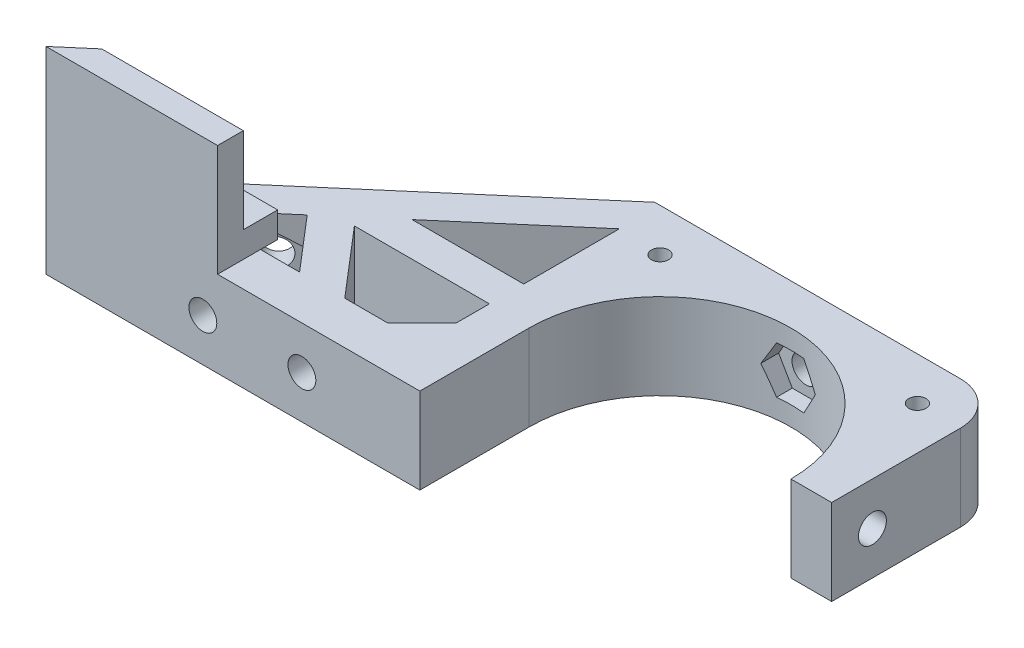
from build123d import *

# Parameters (mm, degrees)
CROQUIS1_R                              = 15.25
CROQUIS1_R_2                            = 2.125
SOPORTE_CAJA_REDUCTORA_DEPTH            = 20
CROQUIS3_R                              = 2.125
CORTAR_EXTRUIR1_DEPTH                   = 51.423828692
REDONDEO1_R                             = 5
BOSS_EXTRUDE1_DEPTH                     = 20
CUT_EXTRUDE1_REACH                      = 55.852
SKETCH2_R                               = 1.625
CUT_EXTRUDE2_DEPTH                      = 2
SKETCH4_R                               = 1.625
CUT_EXTRUDE3_DEPTH                      = 63.291652731
CUT_EXTRUDE4_START                      = -4.5
CUT_EXTRUDE4_DEPTH                      = 2
CROQUIS6_W                              = 4.75
CROQUIS6_H                              = 4.75
CORTAR_EXTRUIR17_DEPTH                  = 42.231056256
CROQUIS7_W                              = 60
CROQUIS7_H                              = 20
CORTAR_EXTRUIR18_DEPTH                  = 51.423828692
SALIENTE_EXTRUIR2_DEPTH                 = 49
SOPORTE_START                           = -15
SOPORTE_MOTOR_DEPTH                     = 15
CROQUIS12_R                             = 2.125
AGUJEROS_DE_SUJECION_A_BASE_DEPTH       = 84.087679592
TUERCA_START                            = -4
TUERCA_AGUJERO_DE_SUJECION_A_BASE_DEPTH = 10
SALIENTE_EXTRUIR4_DEPTH                 = 15
CORTAR_EXTRUIR19_DEPTH                  = 25
CROQUIS14_W                             = 50
CROQUIS14_H                             = 118
CORTAR_EXTRUIR22_DEPTH                  = 146.556045907
CROQUIS15_W                             = 10
CROQUIS15_H                             = 7
CORTAR_EXTRUIR23_DEPTH                  = 42.231056256
CORTAR_EXTRUIR24_DEPTH                  = 42.231056256
CROQUIS18_W                             = 40
CROQUIS18_H                             = 10
CORTAR_EXTRUIR25_DEPTH                  = 44.27311521
SALIENTE_EXTRUIR5_DEPTH                 = 10
CROQUIS20_R                             = 1
CORTAR_EXTRUIR26_DEPTH                  = 49.229270158
CORTAR_EXTRUIR27_REACH                  = 62.959
CORTAR_EXTRUIR27_END_RADIUS             = 15.25
CROQUIS21_R                             = 1.625
CROQUIS22_R                             = 2.125
CROQUIS22_R_2                           = 1
SALIENTE_EXTRUIR6_DEPTH                 = 10
CROQUIS23_R                             = 1.625
CORTAR_EXTRUIR28_DEPTH                  = 52.269508521
CORTAR_EXTRUIR29_START                  = -3
CORTAR_EXTRUIR29_DEPTH                  = 10
SALIENTE_EXTRUIR7_DEPTH                 = 10
CORTAR_EXTRUIR30_REACH                  = 72.235
CROQUIS27_R                             = 1.625
CORTAR_EXTRUIR31_REACH                  = 75.235
CORTAR_EXTRUIR31_START                  = -3
CORTAR_EXTRUIR32_REACH                  = 58.612
CROQUIS29_R                             = 1.625
CORTAR_EXTRUIR33_REACH                  = 61.112
CORTAR_EXTRUIR33_START                  = -2.5
CROQUIS35_W                             = 13.305418987
CROQUIS35_H                             = 6.826864192
CORTAR_EXTRUIR34_DEPTH                  = 63.931555098
CORTAR_EXTRUIR34_DEPTH_BACK             = 63.931555098
CORTAR_EXTRUIR35_START                  = -3
CORTAR_EXTRUIR35_DEPTH                  = 10
SALIENTE_EXTRUIR8_DEPTH                 = 10
SALIENTE_EXTRUIR9_DEPTH                 = 13
SALIENTE_EXTRUIR10_DEPTH                = 3
CROQUIS40_W                             = 106.583537839
CROQUIS40_H                             = 47.391515964
CORTAR_EXTRUIR36_DEPTH                  = 80.887064817
CORTAR_EXTRUIR36_DEPTH_BACK             = 80.887064817


with BuildPart() as part:
    # Croquis1 → Soporte caja reductora (new body)
    with BuildSketch(Plane(origin=(0, 0, 0), x_dir=(1, 0, 0), z_dir=(0, 1, 0))):
        Polygon((-30, -15.25), (-20, -15.25), (-20, -20), (20, -20), (20, -15.25), (30, -15.25), (30, -7.25), (20, -4.25), (20, 20), (-20, 20), (-20, -4.25), (-30, -7.25), align=None)
        with Locations(Location((0, 0, 0), (0, 0, 270))):
            Circle(CROQUIS1_R, mode=Mode.SUBTRACT)
        with Locations(Location((-15, 15, 0), (0, 0, 270))):
            Circle(CROQUIS1_R_2, mode=Mode.SUBTRACT)
        with Locations(Location((15, 15, 0), (0, 0, 270))):
            Circle(CROQUIS1_R_2, mode=Mode.SUBTRACT)
    extrude(amount=-SOPORTE_CAJA_REDUCTORA_DEPTH)

    # Croquis3 → Cortar-Extruir1 (cut, through all)
    with BuildSketch(Plane.XY.offset(15.25)):
        with Locations((-23.5, -10)):
            Circle(CROQUIS3_R)
        with Locations((23.5, -10)):
            Circle(CROQUIS3_R)
    extrude(amount=-CORTAR_EXTRUIR1_DEPTH, mode=Mode.SUBTRACT)

    # Redondeo1
    redondeo1_edges = [part.edges().sort_by_distance(p)[0] for p in [
        (-20, -10, -20),
        (20, -10, -20),
    ]]
    fillet(redondeo1_edges, radius=REDONDEO1_R)

    # Sketch1 → Boss-Extrude1 (add)
    with BuildSketch(Plane(origin=(0, 0, 0), x_dir=(1, 0, 0), z_dir=(0, 1, 0))):
        with BuildLine():
            Line((25.5, 15), (20, 15))
            ThreePointArc((20, 15), (18.535533906, 18.535533906), (15, 20))
            Line((15, 20), (30, 20))
            Line((30, 20), (30, 8))
            Line((30, 8), (25.5, 8))
            Line((25.5, 8), (25.5, 15))
        make_face()
    extrude(amount=-BOSS_EXTRUDE1_DEPTH)

    # Sketch2 → Cut-Extrude1 (cut, up to next)
    with BuildSketch(Plane(origin=(0, 0, -20), x_dir=(-1, 0, 0), z_dir=(0, 0, -1)), mode=Mode.PRIVATE) as cut_extrude1_sk1:
        with Locations((-22.75, -10)):
            Circle(SKETCH2_R)
    cut_extrude1_tool1 = extrude(cut_extrude1_sk1.sketch, amount=-CUT_EXTRUDE1_REACH, mode=Mode.PRIVATE) & part.part
    add(cut_extrude1_tool1.solids().sort_by_distance((22.75, -10, -20))[0], mode=Mode.SUBTRACT)

    # Sketch3 → Cut-Extrude2 (cut)
    with BuildSketch(Plane.XY.offset(-15)):
        Polygon((20, -11.58771324), (22.75, -13.175426481), (25.5, -11.58771324), (25.5, -8.41228676), (22.75, -6.824573519), (20, -8.41228676), align=None)
    extrude(amount=-CUT_EXTRUDE2_DEPTH, mode=Mode.SUBTRACT)

    # Sketch4 → Cut-Extrude3 (cut, through all)
    with BuildSketch(Plane.ZY.offset(-25.5)):
        with Locations((-12.25, -10)):
            Circle(SKETCH4_R)
    extrude(amount=-CUT_EXTRUDE3_DEPTH, mode=Mode.SUBTRACT)

    # Sketch5 → Cut-Extrude4 (cut)
    with BuildSketch(Plane(origin=(30, 0, 0), x_dir=(0, 0, -1), z_dir=(1, 0, 0)).offset(CUT_EXTRUDE4_START)):
        Polygon((15, -11.58771324), (15, -8.41228676), (12.25, -6.824573519), (9.5, -8.41228676), (9.5, -11.58771324), (12.25, -13.175426481), align=None)
    extrude(amount=CUT_EXTRUDE4_DEPTH, mode=Mode.SUBTRACT)

    # Croquis6 → Cortar-Extruir17 (cut, through all)
    with BuildSketch(Plane(origin=(0, 0, 0), x_dir=(1, 0, 0), z_dir=(0, 1, 0))):
        Polygon((0, -15.25), (-15.25, -15.25), (-15.25, -20), (15.25, -20), (15.25, -15.25), align=None)
        with Locations((-17.625, -17.625)):
            Rectangle(CROQUIS6_W, CROQUIS6_H)
        with BuildLine():
            ThreePointArc((0, -15.25), (-10.783378413, -10.783378413), (-15.25, 0))
            Line((-15.25, 0), (-15.25, -15.25))
            Line((-15.25, -15.25), (0, -15.25))
        make_face()
        with BuildLine():
            Line((15.25, -15.25), (15.25, 0))
            ThreePointArc((15.25, 0), (10.783378413, -10.783378413), (0, -15.25))
            Line((0, -15.25), (15.25, -15.25))
        make_face()
        with Locations((17.625, -17.625)):
            Rectangle(CROQUIS6_W, CROQUIS6_H)
    extrude(amount=-CORTAR_EXTRUIR17_DEPTH, mode=Mode.SUBTRACT)


with BuildPart() as body_2:
    # Simetría1: mirrored copy
    add(part.part.mirror(Plane.ZX))

    # Croquis8 → Saliente-Extruir2 (add)
    with BuildSketch(Plane(origin=(0, 20, 0), x_dir=(1, 0, 0), z_dir=(0, 1, 0))):
        with BuildLine():
            Line((-12.664515522, 20), (-11.040489496, 13.939052358))
            Line((-11.040489496, 13.939052358), (-10.315162126, 11.232093763))
            ThreePointArc((-10.315162126, 11.232093763), (0, 15.25), (10.315162126, 11.232093763))
            Line((10.315162126, 11.232093763), (10.817418481, 13.87928066))
            Line((10.817418481, 13.87928066), (11.978715476, 20))
            Line((11.978715476, 20), (-12.664515522, 20))
        make_face()
    extrude(amount=SALIENTE_EXTRUIR2_DEPTH)

    # Croquis9 → Soporte motor (add)
    with BuildSketch(Plane(origin=(0, 69, 0), x_dir=(1, 0, 0), z_dir=(0, 1, 0)).offset(SOPORTE_START)):
        with BuildLine():
            Line((-20, 15), (-20, -4.25))
            Line((-20, -4.25), (-30, -7.25))
            Line((-30, -7.25), (-30, -15.25))
            Line((-30, -15.25), (0, -15.25))
            Line((0, -15.25), (0, -14.75))
            ThreePointArc((0, -14.75), (-10.429825023, 10.429825023), (14.75, 0))
            Line((14.75, 0), (20, 0))
            Line((20, 0), (20, 13.936837101))
            Line((20, 13.936837101), (12.664515522, 20))
            Line((12.664515522, 20), (-15, 20))
            ThreePointArc((-15, 20), (-18.535533906, 18.535533906), (-20, 15))
        make_face()
    extrude(amount=-SOPORTE_MOTOR_DEPTH)

    # Croquis12 → Agujeros de sujecion a base (cut, through all)
    with BuildSketch(Plane.XY.offset(15.25)):
        with Locations((-23.5, 46.5)):
            Circle(CROQUIS12_R)
    extrude(amount=-AGUJEROS_DE_SUJECION_A_BASE_DEPTH, mode=Mode.SUBTRACT)

    # Croquis13 → Tuerca Agujero de sujecion a base (cut)
    with BuildSketch(Plane.XY.offset(15.25).offset(TUERCA_START)):
        Polygon((-20, 44.479274058), (-20, 48.520725942), (-23.5, 50.541451884), (-27, 48.520725942), (-27, 44.479274058), (-23.5, 42.458548116), align=None)
    extrude(amount=-TUERCA_AGUJERO_DE_SUJECION_A_BASE_DEPTH, mode=Mode.SUBTRACT)

    # Croquis10 → Saliente-Extruir4 (add)
    with BuildSketch(Plane(origin=(0, 69, 0), x_dir=(1, 0, 0), z_dir=(0, 1, 0))):
        with BuildLine():
            ThreePointArc((10.315162126, 11.232093763), (0, 15.25), (-10.315162126, 11.232093763))
            Line((-10.315162126, 11.232093763), (-10.16850369, 10.684757026))
            ThreePointArc((-10.16850369, 10.684757026), (0, 14.75), (10.16850369, 10.684757026))
            Line((10.16850369, 10.684757026), (10.315162126, 11.232093763))
        make_face()
    extrude(amount=-SALIENTE_EXTRUIR4_DEPTH)

    # Croquis11 → Cortar-Extruir19 (cut)
    with BuildSketch(Plane.XZ):
        with BuildLine():
            Line((15.25, 4.25), (20, 4.25))
            Line((20, 4.25), (21.972856468, 4.84185694))
            ThreePointArc((21.972856468, 4.84185694), (19.948931102, 10.40625523), (16.543503257, 15.25))
            Line((16.543503257, 15.25), (15.25, 15.25))
            Line((15.25, 15.25), (15.25, 4.25))
        make_face()
        with BuildLine():
            Line((21.972856468, 4.84185694), (30, 7.25))
            Line((30, 7.25), (30, 15.25))
            Line((30, 15.25), (16.543503257, 15.25))
            ThreePointArc((16.543503257, 15.25), (19.948931102, 10.40625523), (21.972856468, 4.84185694))
        make_face()
        with BuildLine():
            ThreePointArc((20, -15), (18.535533906, -18.535533906), (15, -20))
            Line((15, -20), (30, -20))
            Line((30, -20), (30, -8))
            Line((30, -8), (25.5, -8))
            Line((25.5, -8), (25.5, -15))
            Line((25.5, -15), (20, -15))
        make_face()
    extrude(amount=-CORTAR_EXTRUIR19_DEPTH, mode=Mode.SUBTRACT)

    # Simetría2: body 2 across face


with BuildPart() as part_1:
    add(part.part)

    # Croquis7 → Cortar-Extruir18 (cut, through all)
    with BuildSketch(Plane(origin=(0, 0, -20), x_dir=(-1, 0, 0), z_dir=(0, 0, -1))):
        with Locations((0, -10)):
            Rectangle(CROQUIS7_W, CROQUIS7_H)
    extrude(amount=-CORTAR_EXTRUIR18_DEPTH, mode=Mode.SUBTRACT)


with BuildPart() as body_2_1:
    add(body_2.part)
    add(body_2.part.mirror(Plane(origin=(-0.229209569, 69, -16.663998028), x_dir=(0, 0, 1), z_dir=(0, 1, 0))))

    # Croquis14 → Cortar-Extruir22 (cut, through all)
    with BuildSketch(Plane.XY.offset(15.25)):
        with Locations((-5, 79)):
            Rectangle(CROQUIS14_W, CROQUIS14_H)
    extrude(amount=-CORTAR_EXTRUIR22_DEPTH, mode=Mode.SUBTRACT)

    # Croquis15 → Cortar-Extruir23 (cut, through all)
    with BuildSketch(Plane.XZ):
        with Locations((-25, 7.75)):
            Rectangle(CROQUIS15_W, CROQUIS15_H)
    extrude(amount=-CORTAR_EXTRUIR23_DEPTH, mode=Mode.SUBTRACT)

    # Croquis16 → Cortar-Extruir24 (cut, through all)
    with BuildSketch(Plane.XZ):
        Polygon((-30, 15.25), (-15.25, 15.25), (-15.25, 12.75), (-20, 12.75), (-20, 11.25), (-30, 11.25), (-30, 12.75), align=None)
    extrude(amount=-CORTAR_EXTRUIR24_DEPTH, mode=Mode.SUBTRACT)

    # Croquis18 → Cortar-Extruir25 (cut, through all)
    with BuildSketch(Plane(origin=(0, 0, -20), x_dir=(-1, 0, 0), z_dir=(0, 0, -1))):
        with Locations((0, 5)):
            Rectangle(CROQUIS18_W, CROQUIS18_H)
    extrude(amount=-CORTAR_EXTRUIR25_DEPTH, mode=Mode.SUBTRACT)

    # Croquis19 → Saliente-Extruir5 (add)
    with BuildSketch(Plane(origin=(0, 20, 0), x_dir=(1, 0, 0), z_dir=(0, 1, 0))):
        Polygon((-20, -12.75), (-34, -12.75), (-34, -7.75), (-24, -7.75), (-20, -3.75), align=None)
    extrude(amount=-SALIENTE_EXTRUIR5_DEPTH)

    # Croquis20 → Cortar-Extruir26 (cut, through all)
    with BuildSketch(Plane(origin=(0, 0, 7.75), x_dir=(-1, 0, 0), z_dir=(0, 0, -1))):
        with Locations((29, 15)):
            Circle(CROQUIS20_R)
    extrude(amount=-CORTAR_EXTRUIR26_DEPTH, mode=Mode.SUBTRACT)

    # Cortar-Extruir27: up to this cylinder (the profile starts outside it)
    cortar_extruir27_end = Plane(origin=(0, 15, 0), z_dir=(0, -1, 0)) * Cylinder(CORTAR_EXTRUIR27_END_RADIUS, 157.418, mode=Mode.PRIVATE)
    # Croquis21 → Cortar-Extruir27 (cut, up to the surface)
    with BuildSketch(Plane(origin=(20, 0, 0), x_dir=(0, 0, -1), z_dir=(1, 0, 0)), mode=Mode.PRIVATE) as cortar_extruir27_sk1:
        with Locations((4.75, 15)):
            Circle(CROQUIS21_R)
    cortar_extruir27_tool1 = extrude(cortar_extruir27_sk1.sketch, amount=-CORTAR_EXTRUIR27_REACH, mode=Mode.PRIVATE) - cortar_extruir27_end
    add(cortar_extruir27_tool1.solids().sort_by_distance((20, 15, -4.75))[0], mode=Mode.SUBTRACT)

    # Croquis22 → Saliente-Extruir6 (add)
    with BuildSketch(Plane.XZ.offset(-10)):
        with Locations((-15, -15)):
            Circle(CROQUIS22_R)
        with Locations(Location((-15, -15, 0), (0, 0, 270))):
            Circle(CROQUIS22_R_2, mode=Mode.SUBTRACT)
        with Locations((15, -15)):
            Circle(CROQUIS22_R)
        with Locations(Location((15, -15, 0), (0, 0, 270))):
            Circle(CROQUIS22_R_2, mode=Mode.SUBTRACT)
    extrude(amount=-SALIENTE_EXTRUIR6_DEPTH)

    # Croquis23 → Cortar-Extruir28 (cut, through all)
    with BuildSketch(Plane(origin=(0, 0, -20), x_dir=(-1, 0, 0), z_dir=(0, 0, -1))):
        with Locations((0, 15)):
            Circle(CROQUIS23_R)
    extrude(amount=-CORTAR_EXTRUIR28_DEPTH, mode=Mode.SUBTRACT)

    # Croquis24 → Cortar-Extruir29 (cut)
    with BuildSketch(Plane(origin=(0, 0, -20), x_dir=(-1, 0, 0), z_dir=(0, 0, -1)).offset(CORTAR_EXTRUIR29_START)):
        Polygon((1.58771324, 12.25), (3.175426481, 15), (1.58771324, 17.75), (-1.58771324, 17.75), (-3.175426481, 15), (-1.58771324, 12.25), align=None)
    extrude(amount=-CORTAR_EXTRUIR29_DEPTH, mode=Mode.SUBTRACT)

    # Croquis26 → Saliente-Extruir7 (add)
    with BuildSketch(Plane.XZ.offset(-10)):
        Polygon((-34, 7.75), (-34, 12.75), (-58.825, 12.75), (-39.160527763, -4.104491148), (-20, -4.104491148), (-20, -0.104491148), (-35.732113118, -0.104491148), (-29, 7.75), align=None)
        Polygon((-34.268209086, 7.75), (-39.594516123, 1.535690951), (-46.844874897, 7.75), align=None, mode=Mode.SUBTRACT)
    extrude(amount=-SALIENTE_EXTRUIR7_DEPTH)

    # Croquis27 → Cortar-Extruir30 (cut, up to next)
    with BuildSketch(Plane.XY.offset(12.75), mode=Mode.PRIVATE) as cortar_extruir30_sk1:
        with Locations((-40.544874897, 15)):
            Circle(CROQUIS27_R)
    cortar_extruir30_tool1 = extrude(cortar_extruir30_sk1.sketch, amount=-CORTAR_EXTRUIR30_REACH, mode=Mode.PRIVATE) & body_2_1.part
    # Croquis27 → Cortar-Extruir30 (cut, up to next)
    with BuildSketch(Plane.XY.offset(12.75), mode=Mode.PRIVATE) as cortar_extruir30_sk2:
        with Locations((-29, 15)):
            Circle(CROQUIS27_R)
    cortar_extruir30_tool2 = extrude(cortar_extruir30_sk2.sketch, amount=-CORTAR_EXTRUIR30_REACH, mode=Mode.PRIVATE) & body_2_1.part
    add(cortar_extruir30_tool1.solids().sort_by_distance((-40.544875, 15, 12.75))[0], mode=Mode.SUBTRACT)
    add(cortar_extruir30_tool2.solids().sort_by_distance((-29, 15, 12.75))[0], mode=Mode.SUBTRACT)

    # Croquis28 → Cortar-Extruir31 (cut, up to next)
    with BuildSketch(Plane.XY.offset(12.75).offset(CORTAR_EXTRUIR31_START), mode=Mode.PRIVATE) as cortar_extruir31_sk1:
        Polygon((-38.957161657, 12.25), (-37.369448416, 15), (-38.957161657, 17.75), (-42.132588137, 17.75), (-43.720301378, 15), (-42.132588137, 12.25), align=None)
    cortar_extruir31_tool1 = extrude(cortar_extruir31_sk1.sketch, amount=-CORTAR_EXTRUIR31_REACH, mode=Mode.PRIVATE) & body_2_1.part
    # Croquis28 → Cortar-Extruir31 (cut, up to next)
    with BuildSketch(Plane.XY.offset(12.75).offset(CORTAR_EXTRUIR31_START), mode=Mode.PRIVATE) as cortar_extruir31_sk2:
        Polygon((-27.41228676, 12.25), (-25.824573519, 15), (-27.41228676, 17.75), (-30.58771324, 17.75), (-32.175426481, 15), (-30.58771324, 12.25), align=None)
    cortar_extruir31_tool2 = extrude(cortar_extruir31_sk2.sketch, amount=-CORTAR_EXTRUIR31_REACH, mode=Mode.PRIVATE) & body_2_1.part
    add(cortar_extruir31_tool1.solids().sort_by_distance((-40.544875, 15, 9.75))[0], mode=Mode.SUBTRACT)
    add(cortar_extruir31_tool2.solids().sort_by_distance((-29, 15, 9.75))[0], mode=Mode.SUBTRACT)

    # Croquis29 → Cortar-Extruir32 (cut, up to next)
    with BuildSketch(Plane(origin=(-18.612848159, 0, -21.715982563), x_dir=(-0.7592713073348843, 0, 0.6507742172658468), z_dir=(-0.6507742172658468, 0, -0.7592713073348843)), mode=Mode.PRIVATE) as cortar_extruir32_sk1:
        with Locations((33.812368097, 15)):
            Circle(CROQUIS29_R)
    cortar_extruir32_tool1 = extrude(cortar_extruir32_sk1.sketch, amount=-CORTAR_EXTRUIR32_REACH, mode=Mode.PRIVATE) & body_2_1.part
    add(cortar_extruir32_tool1.solids().sort_by_distance((-44.285609, 15, 0.288235))[0], mode=Mode.SUBTRACT)

    # Croquis31 → Cortar-Extruir33 (cut, up to next)
    with BuildSketch(Plane(origin=(-18.612848159, 0, -21.715982563), x_dir=(-0.7592713073348843, 0, 0.6507742172658468), z_dir=(-0.6507742172658468, 0, -0.7592713073348843)).offset(CORTAR_EXTRUIR33_START), mode=Mode.PRIVATE) as cortar_extruir33_sk1:
        Polygon((36.562368097, 16.58771324), (33.812368097, 18.175426481), (31.062368097, 16.58771324), (31.062368097, 13.41228676), (33.812368097, 11.824573519), (36.562368097, 13.41228676), align=None)
    cortar_extruir33_tool1 = extrude(cortar_extruir33_sk1.sketch, amount=-CORTAR_EXTRUIR33_REACH, mode=Mode.PRIVATE) & body_2_1.part
    add(cortar_extruir33_tool1.solids().sort_by_distance((-42.658674, 15, 2.186413))[0], mode=Mode.SUBTRACT)

    # Croquis35 → Cortar-Extruir34 (cut, two sides)
    with BuildSketch(Plane(origin=(0, 20, 0), x_dir=(1, 0, 0), z_dir=(0, 1, 0))) as cortar_extruir34_sk:
        with Locations((17.04227466, -3.413432096)):
            Rectangle(CROQUIS35_W, CROQUIS35_H)
    extrude(amount=CORTAR_EXTRUIR34_DEPTH, mode=Mode.SUBTRACT)
    extrude(cortar_extruir34_sk.sketch, amount=-CORTAR_EXTRUIR34_DEPTH_BACK, mode=Mode.SUBTRACT)

    # Croquis36 → Cortar-Extruir35 (cut)
    with BuildSketch(Plane(origin=(20, 0, 0), x_dir=(0, 0, -1), z_dir=(1, 0, 0)).offset(CORTAR_EXTRUIR35_START)):
        Polygon((7.5, 16.58771324), (4.75, 18.175426481), (2, 16.58771324), (2, 13.41228676), (4.75, 11.824573519), (7.5, 13.41228676), align=None)
    extrude(amount=-CORTAR_EXTRUIR35_DEPTH, mode=Mode.SUBTRACT)

    # Croquis37 → Saliente-Extruir8 (add)
    with BuildSketch(Plane.XZ.offset(-10)):
        Polygon((-39.160527763, -4.104491148), (-20.614919368, -20), (-15, -20), (-19.558128305, -15.637570403), (-33.014002756, -4.104491148), align=None)
    extrude(amount=-SALIENTE_EXTRUIR8_DEPTH)

    # Croquis38 → Saliente-Extruir9 (add)
    with BuildSketch(Plane.XZ.offset(-10)):
        Polygon((-58.825, 12.75), (-38.825, 12.75), (-38.825, 9.75), (-55.324839942, 9.75), align=None)
    extrude(amount=SALIENTE_EXTRUIR9_DEPTH)

    # Croquis39 → Saliente-Extruir10 (add)
    with BuildSketch(Plane.XZ.offset(-10)):
        Polygon((-38.825, 9.75), (-38.825, 7.75), (-38.825, 5.75), (-50.657959865, 5.75), (-52.991399903, 7.75), (-55.324839942, 9.75), align=None)
    extrude(amount=SALIENTE_EXTRUIR10_DEPTH)

    # Simetría3: body 2 across face


with BuildPart() as body_2_2:
    add(body_2_1.part)
    add(body_2_1.part.mirror(Plane(origin=(-18.003999227, 20, -4.220503046), x_dir=(0, 0, 1), z_dir=(0, 1, 0))))

    # Croquis40 → Cortar-Extruir36 (cut, two sides)
    with BuildSketch(Plane(origin=(0, 0, -20), x_dir=(-1, 0, 0), z_dir=(0, 0, -1))) as cortar_extruir36_sk:
        with Locations((22.395502026, -3.695757982)):
            Rectangle(CROQUIS40_W, CROQUIS40_H)
    extrude(amount=CORTAR_EXTRUIR36_DEPTH, mode=Mode.SUBTRACT)
    extrude(cortar_extruir36_sk.sketch, amount=-CORTAR_EXTRUIR36_DEPTH_BACK, mode=Mode.SUBTRACT)


solid = body_2_2.part
